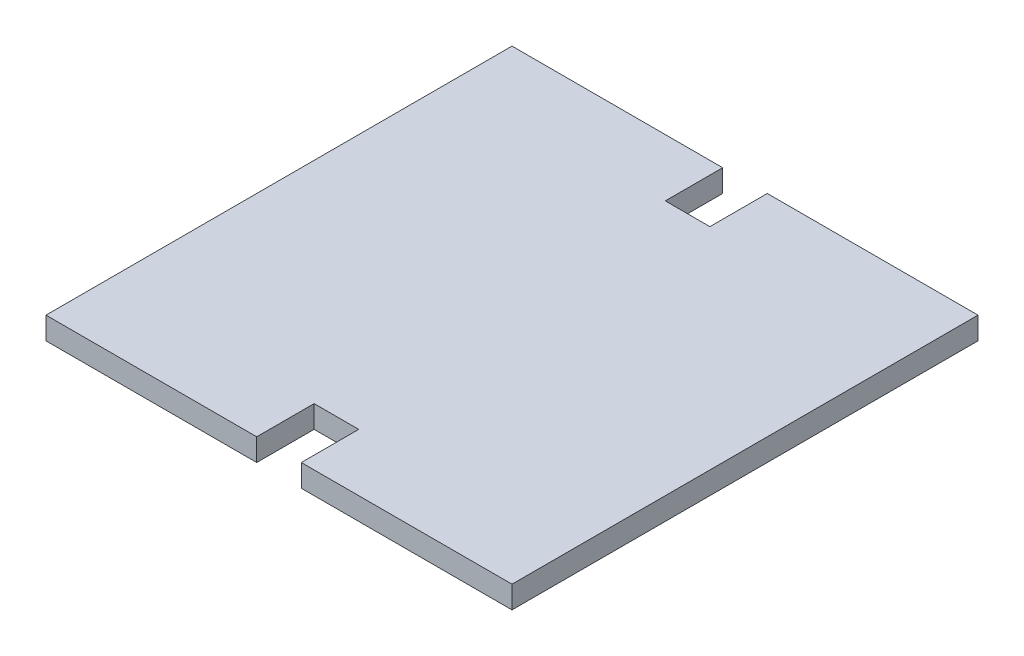
from build123d import *

# Parameters (mm, degrees)
SKETCH1_W           = 132.7
SKETCH1_H           = 132.7
BOSS_EXTRUDE2_DEPTH = 6.35
SKETCH5_W           = 12.7
SKETCH5_H           = 16.35
CUT_EXTRUDE1_DEPTH  = 95.047687372
CIRPATTERN1_COUNT   = 2


with BuildPart() as part:
    # Sketch1 → Boss-Extrude2 (new body)
    with BuildSketch(Plane(origin=(0, 0, 0), x_dir=(1, 0, 0), z_dir=(0, 1, 0))):
        Rectangle(SKETCH1_W, SKETCH1_H)
    extrude(amount=BOSS_EXTRUDE2_DEPTH)

    # Sketch5 → Cut-Extrude1 (cut, through all)
    with BuildSketch(Plane(origin=(0, 6.35, 0), x_dir=(1, 0, 0), z_dir=(0, 1, 0))):
        with Locations((0, 58.175)):
            Rectangle(SKETCH5_W, SKETCH5_H)
    cut_extrude1 = extrude(amount=-CUT_EXTRUDE1_DEPTH, mode=Mode.SUBTRACT)

    # CirPattern1: Cut-Extrude1 ×2 about axis
    cirpattern1_axis = Axis((0, 6.35, 0), (0, 1, 0))
    for i in range(1, CIRPATTERN1_COUNT):
        add(cut_extrude1.rotate(cirpattern1_axis, i * 360 / CIRPATTERN1_COUNT), mode=Mode.SUBTRACT)


solid = part.part
